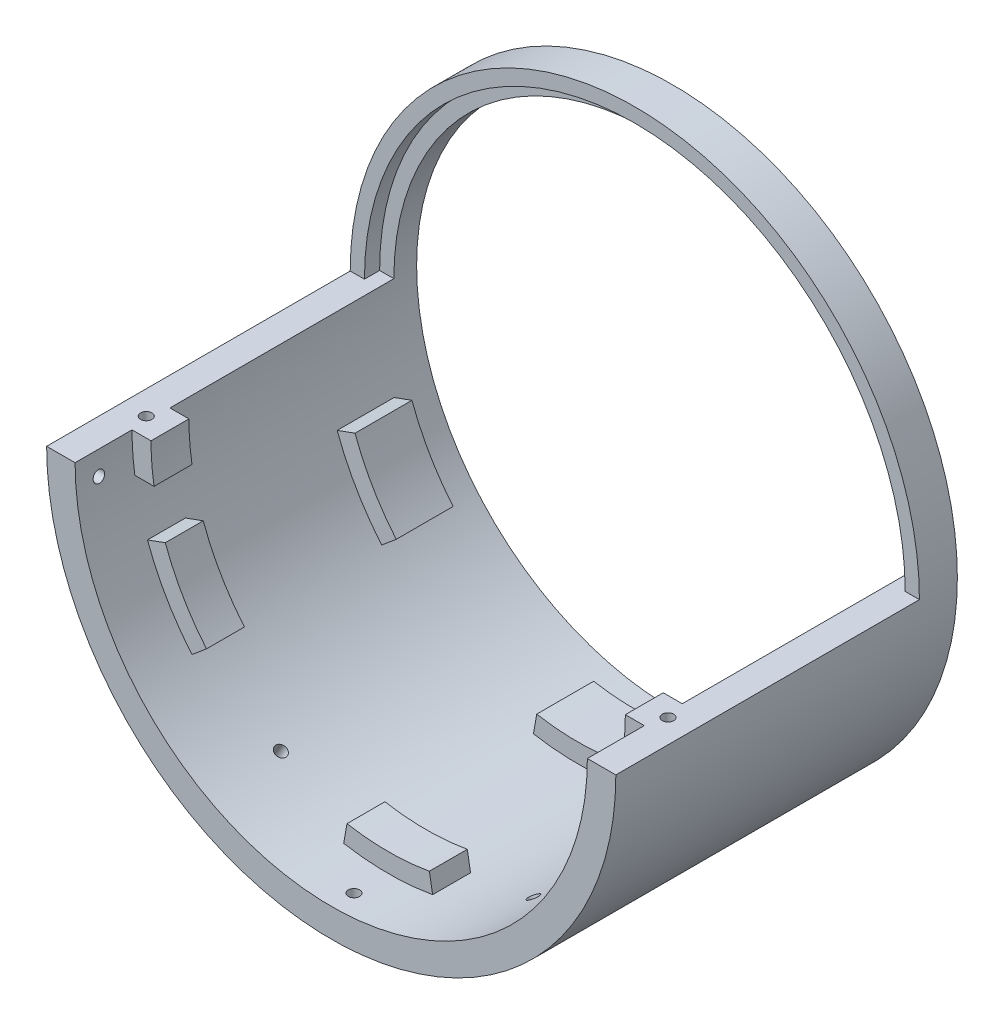
from build123d import *

# Parameters (mm, degrees)
SKETCH2_R               = 75
SKETCH2_R_2             = 67.5
BOSS_EXTRUDE2_DEPTH     = 10
BOSS_EXTRUDE3_DEPTH     = 80
BOSS_EXTRUDE4_DEPTH     = 15
BOSS_EXTRUDE5_DEPTH     = 10
SKETCH7_W               = 10
SKETCH7_H               = 10
BOSS_EXTRUDE6_DEPTH     = 137
SKETCH8_R               = 62.5
CUT_EXTRUDE1_DEPTH      = 150
SKETCH9_R               = 1.5
CUT_EXTRUDE2_DEPTH      = 6.5
CUT_EXTRUDE3_DEPTH      = 152.5
CUT_EXTRUDE3_DEPTH_BACK = 6.5
SKETCH10_R              = 1.5
CUT_EXTRUDE4_DEPTH      = 6.5
CUT_EXTRUDE4_DEPTH_BACK = 6.5
SKETCH12_R              = 1.5
CUT_EXTRUDE5_DEPTH      = 6.5
CUT_EXTRUDE5_DEPTH_BACK = 6.5
SKETCH13_R              = 1.5
CUT_EXTRUDE6_DEPTH      = 6.5
CUT_EXTRUDE6_DEPTH_BACK = 6.5
SKETCH14_R              = 1.5
CUT_EXTRUDE7_START      = -4
CUT_EXTRUDE7_DEPTH      = 4


with BuildPart() as part:
    # Sketch2 → Boss-Extrude2 (new body)
    with BuildSketch(Plane.XY):
        Circle(SKETCH2_R)
        Circle(SKETCH2_R_2, mode=Mode.SUBTRACT)
    extrude(amount=BOSS_EXTRUDE2_DEPTH)

    # Sketch3 → Boss-Extrude3 (add)
    with BuildSketch(Plane.XY.offset(10)):
        with BuildLine():
            Line((75, 0), (67.5, 0))
            ThreePointArc((67.5, 0), (0, -67.5), (-67.5, 0))
            Line((-67.5, 0), (-75, 0))
            ThreePointArc((-75, 0), (0, -75), (75, 0))
        make_face()
    extrude(amount=BOSS_EXTRUDE3_DEPTH)

    # Sketch5 → Boss-Extrude4 (add)
    with BuildSketch(Plane.XY.offset(10)):
        with BuildLine():
            ThreePointArc((-47.877777695, -40.174225605), (-54.126587737, -31.25), (-58.730788799, -21.376258958))
            Line((-58.730788799, -21.376258958), (-63.429251903, -23.086359674))
            ThreePointArc((-63.429251903, -23.086359674), (-58.456714755, -33.75), (-51.707999911, -43.388163654))
            Line((-51.707999911, -43.388163654), (-47.877777695, -40.174225605))
        make_face()
        with BuildLine():
            Line((63.429251903, -23.086359674), (58.730788799, -21.376258958))
            ThreePointArc((58.730788799, -21.376258958), (54.126587737, -31.25), (47.877777695, -40.174225605))
            Line((47.877777695, -40.174225605), (51.707999911, -43.388163654))
            ThreePointArc((51.707999911, -43.388163654), (58.456714755, -33.75), (63.429251903, -23.086359674))
        make_face()
        with BuildLine():
            ThreePointArc((10.853011104, -61.550484563), (0, -62.5), (-10.853011104, -61.550484563))
            Line((-10.853011104, -61.550484563), (-11.721251993, -66.474523328))
            ThreePointArc((-11.721251993, -66.474523328), (0, -67.5), (11.721251993, -66.474523328))
            Line((11.721251993, -66.474523328), (10.853011104, -61.550484563))
        make_face()
    extrude(amount=BOSS_EXTRUDE4_DEPTH)

    # Sketch6 → Boss-Extrude5 (add)
    with BuildSketch(Plane.XY.offset(65)):
        with BuildLine():
            ThreePointArc((-47.877777695, -40.174225605), (-54.126587737, -31.25), (-58.730788799, -21.376258958))
            Line((-58.730788799, -21.376258958), (-63.429251903, -23.086359674))
            ThreePointArc((-63.429251903, -23.086359674), (-58.456714755, -33.75), (-51.707999911, -43.388163654))
            Line((-51.707999911, -43.388163654), (-47.877777695, -40.174225605))
        make_face()
        with BuildLine():
            Line((63.429251903, -23.086359674), (58.730788799, -21.376258958))
            ThreePointArc((58.730788799, -21.376258958), (54.126587737, -31.25), (47.877777695, -40.174225605))
            Line((47.877777695, -40.174225605), (51.707999911, -43.388163654))
            ThreePointArc((51.707999911, -43.388163654), (58.456714755, -33.75), (63.429251903, -23.086359674))
        make_face()
        with BuildLine():
            ThreePointArc((10.853011104, -61.550484563), (0, -62.5), (-10.853011104, -61.550484563))
            Line((-10.853011104, -61.550484563), (-11.721251993, -66.474523328))
            ThreePointArc((-11.721251993, -66.474523328), (0, -67.5), (11.721251993, -66.474523328))
            Line((11.721251993, -66.474523328), (10.853011104, -61.550484563))
        make_face()
    extrude(amount=BOSS_EXTRUDE5_DEPTH)

    # Sketch7 → Boss-Extrude6 (add)
    with BuildSketch(Plane.ZY.offset(-67.5)):
        with Locations((70, -5)):
            Rectangle(SKETCH7_W, SKETCH7_H)
    extrude(amount=BOSS_EXTRUDE6_DEPTH)

    # Sketch8 → Cut-Extrude1 (cut)
    with BuildSketch(Plane.XY.offset(10)):
        Circle(SKETCH8_R)
    extrude(amount=CUT_EXTRUDE1_DEPTH, mode=Mode.SUBTRACT)

    # Sketch9 → Cut-Extrude2 (cut)
    with BuildSketch(Plane(origin=(0, 0, 0), x_dir=(1, 0, 0), z_dir=(0, 1, 0))):
        with Locations((-68.75, -70)):
            Circle(SKETCH9_R)
        with Locations((68.75, -70)):
            Circle(SKETCH9_R)
    extrude(amount=-CUT_EXTRUDE2_DEPTH, mode=Mode.SUBTRACT)

    # Sketch10 → Cut-Extrude3 (cut, two sides: drawn at the far end of the back side and taken through both)
    with BuildSketch(Plane.ZY.offset(-67.5).offset(-CUT_EXTRUDE3_DEPTH_BACK)):
        with Locations((84, -6)):
            Circle(SKETCH10_R)
    extrude(amount=CUT_EXTRUDE3_DEPTH + CUT_EXTRUDE3_DEPTH_BACK, mode=Mode.SUBTRACT)

    # Sketch12 → Cut-Extrude4 (cut, two sides: drawn at the far end of the back side and taken through both)
    with BuildSketch(Plane(origin=(0, -67.5, 0), x_dir=(1, 0, 0), z_dir=(0, 1, 0)).offset(-CUT_EXTRUDE4_DEPTH_BACK)):
        with Locations((0, -84)):
            Circle(SKETCH12_R)
    extrude(amount=CUT_EXTRUDE4_DEPTH + CUT_EXTRUDE4_DEPTH_BACK, mode=Mode.SUBTRACT)

    # Sketch13 → Cut-Extrude5 (cut, two sides: drawn at the far end of the back side and taken through both)
    with BuildSketch(Plane(origin=(-33.75, -58.456714755, 0), x_dir=(0.8660254037844395, -0.4999999999999986, 0), z_dir=(0.4999999999999986, 0.8660254037844395, 0)).offset(-CUT_EXTRUDE5_DEPTH_BACK)):
        with Locations((0.543285245, -70)):
            Circle(SKETCH13_R)
    extrude(amount=CUT_EXTRUDE5_DEPTH + CUT_EXTRUDE5_DEPTH_BACK, mode=Mode.SUBTRACT)

    # Sketch14 → Cut-Extrude6 (cut, two sides: drawn at the far end of the back side and taken through both)
    with BuildSketch(Plane(origin=(33.75, -58.456714755, 0), x_dir=(0.8660254037844367, 0.5000000000000034, 0), z_dir=(-0.5000000000000033, 0.8660254037844366, 0)).offset(-CUT_EXTRUDE6_DEPTH_BACK)):
        with Locations((-0.543285245, -70)):
            Circle(SKETCH14_R)
    extrude(amount=CUT_EXTRUDE6_DEPTH + CUT_EXTRUDE6_DEPTH_BACK, mode=Mode.SUBTRACT)

    # Sketch15 → Cut-Extrude7 (cut)
    with BuildSketch(Plane.XY.offset(10).offset(CUT_EXTRUDE7_START)):
        with BuildLine():
            ThreePointArc((71.25, 0), (0, 71.25), (-71.25, 0))
            Line((-71.25, 0), (-67.5, 0))
            ThreePointArc((-67.5, 0), (0, 67.5), (67.5, 0))
            Line((67.5, 0), (71.25, 0))
        make_face()
    extrude(amount=CUT_EXTRUDE7_DEPTH, mode=Mode.SUBTRACT)


solid = part.part
